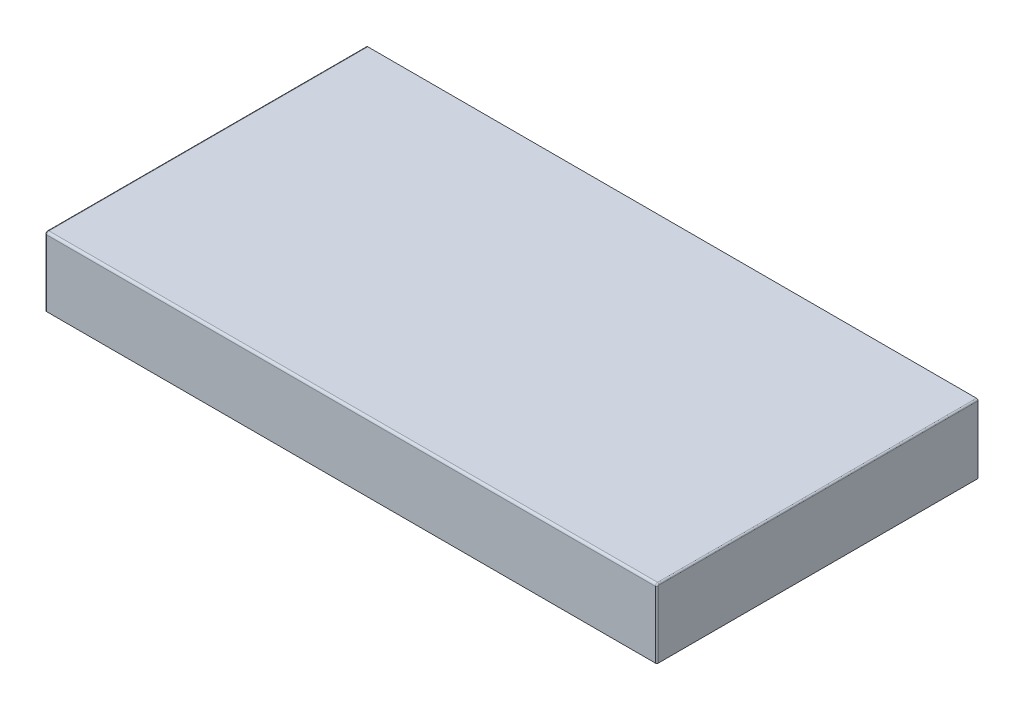
from build123d import *

# Parameters (mm, degrees)
SKETCH2_W           = 800
SKETCH2_H           = 90
BOSS_EXTRUDE1_DEPTH = 210
FILLET1_R           = 3
FILLET2_R           = 2


with BuildPart() as part:
    # Sketch2 → Boss-Extrude1 (new body, symmetric)
    with BuildSketch(Plane.XY):
        Rectangle(SKETCH2_W, SKETCH2_H)
    extrude(amount=BOSS_EXTRUDE1_DEPTH, both=True)

    # Fillet1
    fillet1_edges = [part.edges().sort_by_distance(p)[0] for p in [
        (0, 45, 210),
    ]]
    fillet(fillet1_edges, radius=FILLET1_R)

    # Fillet2
    fillet2_edges = [part.edges().sort_by_distance(p)[0] for p in [
        (-400, -1.5, 210),
        (-400, 45, -1.5),
        (-400, 44.121320344, 209.121320344),
        (400, 45, -1.5),
        (400, 44.121320344, 209.121320344),
        (400, -1.5, 210),
    ]]
    fillet(fillet2_edges, radius=FILLET2_R)


solid = part.part
